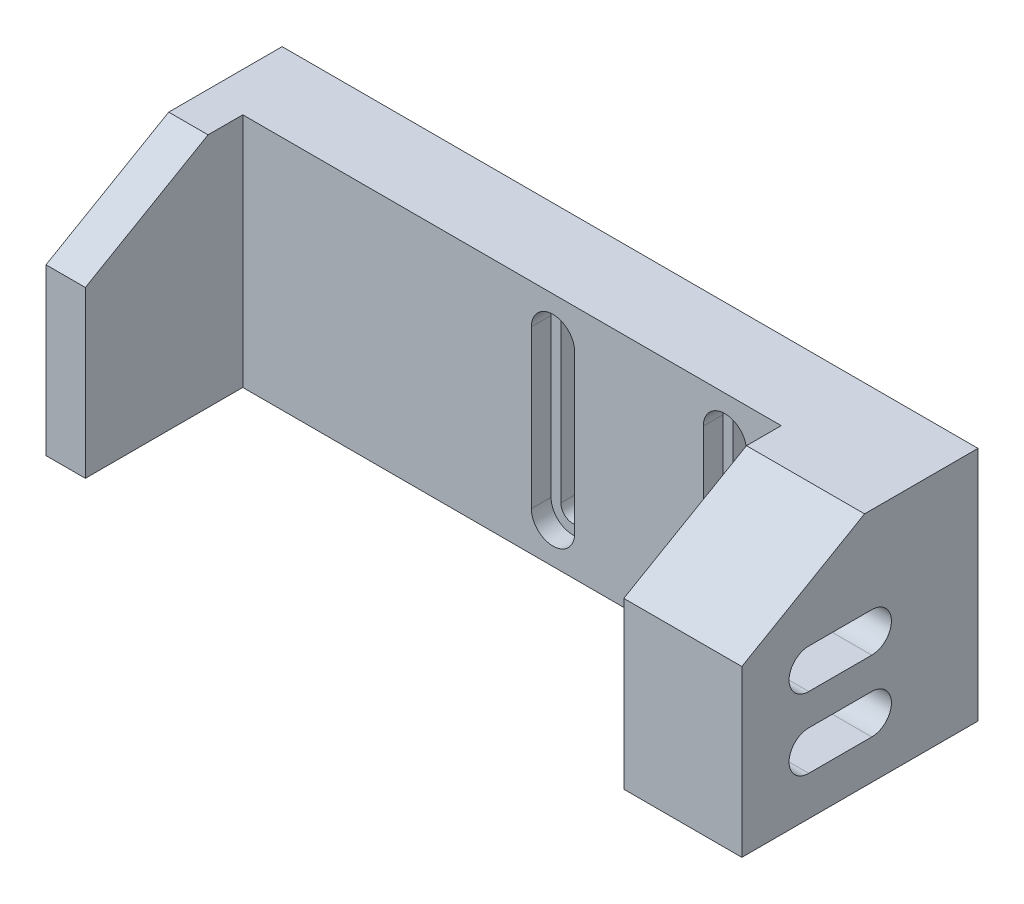
from build123d import *
from OCP.BRepFilletAPI import BRepFilletAPI_MakeChamfer

# Parameters (mm, degrees)
BOSS_EXTRUDE1_DEPTH = 30
CUT_EXTRUDE1_REACH  = 87.273
CHAMFER1_SIZE       = 9
CHAMFER1_SIZE2      = 15.588457268
BOSS_EXTRUDE8_DEPTH = 10
CUT_EXTRUDE2_REACH  = 66.966
CUT_EXTRUDE3_DEPTH  = 2.5


with BuildPart() as part:
    # Sketch1 → Boss-Extrude1 (new body)
    with BuildSketch(Plane(origin=(0, 0, 0), x_dir=(1, 0, 0), z_dir=(0, 1, 0))):
        Polygon((39.2, 15), (-39.2, 15), (-39.2, -15), (-34.2, -15), (-34.2, 5), (34.2, 5), (34.2, -15), (39.2, -15), align=None)
    extrude(amount=BOSS_EXTRUDE1_DEPTH)

    # Sketch2 → Cut-Extrude1 (cut, up to next)
    with BuildSketch(Plane(origin=(39.2, 0, 0), x_dir=(0, 0, -1), z_dir=(1, 0, 0)), mode=Mode.PRIVATE) as cut_extrude1_sk1:
        with BuildLine():
            Line((-6.5, 10), (1.5, 10))
            ThreePointArc((1.5, 10), (4, 7.5), (1.5, 5))
            Line((1.5, 5), (-6.5, 5))
            ThreePointArc((-6.5, 5), (-9, 7.5), (-6.5, 10))
        make_face()
    cut_extrude1_tool1 = extrude(cut_extrude1_sk1.sketch, amount=-CUT_EXTRUDE1_REACH, mode=Mode.PRIVATE) & part.part
    # Sketch2 → Cut-Extrude1 (cut, up to next)
    with BuildSketch(Plane(origin=(39.2, 0, 0), x_dir=(0, 0, -1), z_dir=(1, 0, 0)), mode=Mode.PRIVATE) as cut_extrude1_sk2:
        with BuildLine():
            Line((-6.5, 19), (1.5, 19))
            ThreePointArc((1.5, 19), (4, 16.5), (1.5, 14))
            Line((1.5, 14), (-6.5, 14))
            ThreePointArc((-6.5, 14), (-9, 16.5), (-6.5, 19))
        make_face()
    cut_extrude1_tool2 = extrude(cut_extrude1_sk2.sketch, amount=-CUT_EXTRUDE1_REACH, mode=Mode.PRIVATE) & part.part
    add(cut_extrude1_tool1.solids().sort_by_distance((39.2, 7.5, 2.5))[0], mode=Mode.SUBTRACT)
    add(cut_extrude1_tool2.solids().sort_by_distance((39.2, 16.5, 2.5))[0], mode=Mode.SUBTRACT)

    # Chamfer1: one chamfer whose edges measure the first distance from different faces: ONE call of the kernel's chamfer builder (chamfer() names one face for all edges)
    chamfer1_edges_1 = [part.edges().sort_by_distance(p)[0] for p in [
        (36.7, 30, 15),
    ]]
    chamfer1_side_1 = [part.faces().sort_by_distance(p)[0] for p in [
        (36.7, 15, 15),
    ]]
    chamfer1_edges_2 = [part.edges().sort_by_distance(p)[0] for p in [
        (-36.7, 30, 15),
    ]]
    chamfer1_side_2 = [part.faces().sort_by_distance(p)[0] for p in [
        (-36.7, 15, 15),
    ]]
    chamfer1 = BRepFilletAPI_MakeChamfer(part.part.solid().wrapped)
    for e in chamfer1_edges_1:
        chamfer1.Add(CHAMFER1_SIZE, CHAMFER1_SIZE2, e.wrapped, chamfer1_side_1[0].wrapped)  # the first distance lies on this face
    for e in chamfer1_edges_2:
        chamfer1.Add(CHAMFER1_SIZE, CHAMFER1_SIZE2, e.wrapped, chamfer1_side_2[0].wrapped)  # the first distance lies on this face
    add(Compound.cast(chamfer1.Shape()), mode=Mode.REPLACE)

    # Sketch8 → Boss-Extrude8 (add)
    with BuildSketch(Plane(origin=(39.2, 0, 0), x_dir=(0, 0, -1), z_dir=(1, 0, 0))):
        Polygon((15, 30), (0.588457268, 30), (-15, 21), (-15, 0), (15, 0), align=None)
        with BuildLine():
            Line((-6.5, 19), (1.5, 19))
            ThreePointArc((1.5, 19), (4, 16.5), (1.5, 14))
            Line((1.5, 14), (-6.5, 14))
            ThreePointArc((-6.5, 14), (-9, 16.5), (-6.5, 19))
        make_face(mode=Mode.SUBTRACT)
        with BuildLine():
            Line((-6.5, 10), (1.5, 10))
            ThreePointArc((1.5, 10), (4, 7.5), (1.5, 5))
            Line((1.5, 5), (-6.5, 5))
            ThreePointArc((-6.5, 5), (-9, 7.5), (-6.5, 10))
        make_face(mode=Mode.SUBTRACT)
    extrude(amount=BOSS_EXTRUDE8_DEPTH)

    # Sketch9 → Cut-Extrude2 (cut, up to next)
    with BuildSketch(Plane(origin=(0, 0, -15), x_dir=(-1, 0, 0), z_dir=(0, 0, -1)), mode=Mode.PRIVATE) as cut_extrude2_sk1:
        with BuildLine():
            ThreePointArc((-25.55, 25), (-27.05, 23.5), (-28.55, 25))
            Line((-28.55, 25), (-28.55, 5))
            ThreePointArc((-28.55, 5), (-27.05, 6.5), (-25.55, 5))
            Line((-25.55, 5), (-25.55, 25))
        make_face()
    cut_extrude2_tool1 = extrude(cut_extrude2_sk1.sketch, amount=-CUT_EXTRUDE2_REACH, mode=Mode.PRIVATE) & part.part
    # Sketch9 → Cut-Extrude2 (cut, up to next)
    with BuildSketch(Plane(origin=(0, 0, -15), x_dir=(-1, 0, 0), z_dir=(0, 0, -1)), mode=Mode.PRIVATE) as cut_extrude2_sk2:
        with BuildLine():
            ThreePointArc((-25.55, 25), (-27.05, 26.5), (-28.55, 25))
            Line((-28.55, 25), (-25.55, 25))
        make_face()
    cut_extrude2_tool2 = extrude(cut_extrude2_sk2.sketch, amount=-CUT_EXTRUDE2_REACH, mode=Mode.PRIVATE) & part.part
    # Sketch9 → Cut-Extrude2 (cut, up to next)
    with BuildSketch(Plane(origin=(0, 0, -15), x_dir=(-1, 0, 0), z_dir=(0, 0, -1)), mode=Mode.PRIVATE) as cut_extrude2_sk3:
        with BuildLine():
            Line((-25.55, 25), (-28.55, 25))
            ThreePointArc((-28.55, 25), (-27.05, 23.5), (-25.55, 25))
        make_face()
    cut_extrude2_tool3 = extrude(cut_extrude2_sk3.sketch, amount=-CUT_EXTRUDE2_REACH, mode=Mode.PRIVATE) & part.part
    # Sketch9 → Cut-Extrude2 (cut, up to next)
    with BuildSketch(Plane(origin=(0, 0, -15), x_dir=(-1, 0, 0), z_dir=(0, 0, -1)), mode=Mode.PRIVATE) as cut_extrude2_sk4:
        with BuildLine():
            ThreePointArc((-3.71, 25), (-5.21, 26.5), (-6.71, 25))
            Line((-6.71, 25), (-3.71, 25))
        make_face()
    cut_extrude2_tool4 = extrude(cut_extrude2_sk4.sketch, amount=-CUT_EXTRUDE2_REACH, mode=Mode.PRIVATE) & part.part
    # Sketch9 → Cut-Extrude2 (cut, up to next)
    with BuildSketch(Plane(origin=(0, 0, -15), x_dir=(-1, 0, 0), z_dir=(0, 0, -1)), mode=Mode.PRIVATE) as cut_extrude2_sk5:
        with BuildLine():
            Line((-3.71, 25), (-6.71, 25))
            ThreePointArc((-6.71, 25), (-5.21, 23.5), (-3.71, 25))
        make_face()
    cut_extrude2_tool5 = extrude(cut_extrude2_sk5.sketch, amount=-CUT_EXTRUDE2_REACH, mode=Mode.PRIVATE) & part.part
    # Sketch9 → Cut-Extrude2 (cut, up to next)
    with BuildSketch(Plane(origin=(0, 0, -15), x_dir=(-1, 0, 0), z_dir=(0, 0, -1)), mode=Mode.PRIVATE) as cut_extrude2_sk6:
        with BuildLine():
            ThreePointArc((-3.71, 25), (-5.21, 23.5), (-6.71, 25))
            Line((-6.71, 25), (-6.71, 5))
            ThreePointArc((-6.71, 5), (-5.21, 6.5), (-3.71, 5))
            Line((-3.71, 5), (-3.71, 25))
        make_face()
    cut_extrude2_tool6 = extrude(cut_extrude2_sk6.sketch, amount=-CUT_EXTRUDE2_REACH, mode=Mode.PRIVATE) & part.part
    # Sketch9 → Cut-Extrude2 (cut, up to next)
    with BuildSketch(Plane(origin=(0, 0, -15), x_dir=(-1, 0, 0), z_dir=(0, 0, -1)), mode=Mode.PRIVATE) as cut_extrude2_sk7:
        with BuildLine():
            ThreePointArc((-3.71, 25), (-5.21, 26.5), (-6.71, 25))
            Line((-6.71, 25), (-3.71, 25))
        make_face()
    cut_extrude2_tool7 = extrude(cut_extrude2_sk7.sketch, amount=-CUT_EXTRUDE2_REACH, mode=Mode.PRIVATE) & part.part
    # Sketch9 → Cut-Extrude2 (cut, up to next)
    with BuildSketch(Plane(origin=(0, 0, -15), x_dir=(-1, 0, 0), z_dir=(0, 0, -1)), mode=Mode.PRIVATE) as cut_extrude2_sk8:
        with BuildLine():
            Line((-3.71, 25), (-6.71, 25))
            ThreePointArc((-6.71, 25), (-5.21, 23.5), (-3.71, 25))
        make_face()
    cut_extrude2_tool8 = extrude(cut_extrude2_sk8.sketch, amount=-CUT_EXTRUDE2_REACH, mode=Mode.PRIVATE) & part.part
    # Sketch9 → Cut-Extrude2 (cut, up to next)
    with BuildSketch(Plane(origin=(0, 0, -15), x_dir=(-1, 0, 0), z_dir=(0, 0, -1)), mode=Mode.PRIVATE) as cut_extrude2_sk9:
        with BuildLine():
            ThreePointArc((-25.55, 25), (-27.05, 26.5), (-28.55, 25))
            Line((-28.55, 25), (-25.55, 25))
        make_face()
    cut_extrude2_tool9 = extrude(cut_extrude2_sk9.sketch, amount=-CUT_EXTRUDE2_REACH, mode=Mode.PRIVATE) & part.part
    # Sketch9 → Cut-Extrude2 (cut, up to next)
    with BuildSketch(Plane(origin=(0, 0, -15), x_dir=(-1, 0, 0), z_dir=(0, 0, -1)), mode=Mode.PRIVATE) as cut_extrude2_sk10:
        with BuildLine():
            Line((-25.55, 25), (-28.55, 25))
            ThreePointArc((-28.55, 25), (-27.05, 23.5), (-25.55, 25))
        make_face()
    cut_extrude2_tool10 = extrude(cut_extrude2_sk10.sketch, amount=-CUT_EXTRUDE2_REACH, mode=Mode.PRIVATE) & part.part
    # Sketch9 → Cut-Extrude2 (cut, up to next)
    with BuildSketch(Plane(origin=(0, 0, -15), x_dir=(-1, 0, 0), z_dir=(0, 0, -1)), mode=Mode.PRIVATE) as cut_extrude2_sk11:
        with BuildLine():
            ThreePointArc((-25.55, 5), (-27.05, 6.5), (-28.55, 5))
            Line((-28.55, 5), (-25.55, 5))
        make_face()
    cut_extrude2_tool11 = extrude(cut_extrude2_sk11.sketch, amount=-CUT_EXTRUDE2_REACH, mode=Mode.PRIVATE) & part.part
    # Sketch9 → Cut-Extrude2 (cut, up to next)
    with BuildSketch(Plane(origin=(0, 0, -15), x_dir=(-1, 0, 0), z_dir=(0, 0, -1)), mode=Mode.PRIVATE) as cut_extrude2_sk12:
        with BuildLine():
            Line((-25.55, 5), (-28.55, 5))
            ThreePointArc((-28.55, 5), (-27.05, 3.5), (-25.55, 5))
        make_face()
    cut_extrude2_tool12 = extrude(cut_extrude2_sk12.sketch, amount=-CUT_EXTRUDE2_REACH, mode=Mode.PRIVATE) & part.part
    # Sketch9 → Cut-Extrude2 (cut, up to next)
    with BuildSketch(Plane(origin=(0, 0, -15), x_dir=(-1, 0, 0), z_dir=(0, 0, -1)), mode=Mode.PRIVATE) as cut_extrude2_sk13:
        with BuildLine():
            ThreePointArc((-25.55, 5), (-27.05, 6.5), (-28.55, 5))
            Line((-28.55, 5), (-25.55, 5))
        make_face()
    cut_extrude2_tool13 = extrude(cut_extrude2_sk13.sketch, amount=-CUT_EXTRUDE2_REACH, mode=Mode.PRIVATE) & part.part
    # Sketch9 → Cut-Extrude2 (cut, up to next)
    with BuildSketch(Plane(origin=(0, 0, -15), x_dir=(-1, 0, 0), z_dir=(0, 0, -1)), mode=Mode.PRIVATE) as cut_extrude2_sk14:
        with BuildLine():
            Line((-25.55, 5), (-28.55, 5))
            ThreePointArc((-28.55, 5), (-27.05, 3.5), (-25.55, 5))
        make_face()
    cut_extrude2_tool14 = extrude(cut_extrude2_sk14.sketch, amount=-CUT_EXTRUDE2_REACH, mode=Mode.PRIVATE) & part.part
    # Sketch9 → Cut-Extrude2 (cut, up to next)
    with BuildSketch(Plane(origin=(0, 0, -15), x_dir=(-1, 0, 0), z_dir=(0, 0, -1)), mode=Mode.PRIVATE) as cut_extrude2_sk15:
        with BuildLine():
            ThreePointArc((-3.71, 5), (-5.21, 6.5), (-6.71, 5))
            Line((-6.71, 5), (-3.71, 5))
        make_face()
    cut_extrude2_tool15 = extrude(cut_extrude2_sk15.sketch, amount=-CUT_EXTRUDE2_REACH, mode=Mode.PRIVATE) & part.part
    # Sketch9 → Cut-Extrude2 (cut, up to next)
    with BuildSketch(Plane(origin=(0, 0, -15), x_dir=(-1, 0, 0), z_dir=(0, 0, -1)), mode=Mode.PRIVATE) as cut_extrude2_sk16:
        with BuildLine():
            Line((-3.71, 5), (-6.71, 5))
            ThreePointArc((-6.71, 5), (-5.21, 3.5), (-3.71, 5))
        make_face()
    cut_extrude2_tool16 = extrude(cut_extrude2_sk16.sketch, amount=-CUT_EXTRUDE2_REACH, mode=Mode.PRIVATE) & part.part
    # Sketch9 → Cut-Extrude2 (cut, up to next)
    with BuildSketch(Plane(origin=(0, 0, -15), x_dir=(-1, 0, 0), z_dir=(0, 0, -1)), mode=Mode.PRIVATE) as cut_extrude2_sk17:
        with BuildLine():
            ThreePointArc((-3.71, 5), (-5.21, 6.5), (-6.71, 5))
            Line((-6.71, 5), (-3.71, 5))
        make_face()
    cut_extrude2_tool17 = extrude(cut_extrude2_sk17.sketch, amount=-CUT_EXTRUDE2_REACH, mode=Mode.PRIVATE) & part.part
    # Sketch9 → Cut-Extrude2 (cut, up to next)
    with BuildSketch(Plane(origin=(0, 0, -15), x_dir=(-1, 0, 0), z_dir=(0, 0, -1)), mode=Mode.PRIVATE) as cut_extrude2_sk18:
        with BuildLine():
            Line((-3.71, 5), (-6.71, 5))
            ThreePointArc((-6.71, 5), (-5.21, 3.5), (-3.71, 5))
        make_face()
    cut_extrude2_tool18 = extrude(cut_extrude2_sk18.sketch, amount=-CUT_EXTRUDE2_REACH, mode=Mode.PRIVATE) & part.part
    add(cut_extrude2_tool1.solids().sort_by_distance((27.05, 15, -15))[0], mode=Mode.SUBTRACT)
    add(cut_extrude2_tool2.solids().sort_by_distance((27.05, 25.63662, -15))[0], mode=Mode.SUBTRACT)
    add(cut_extrude2_tool3.solids().sort_by_distance((27.05, 24.36338, -15))[0], mode=Mode.SUBTRACT)
    add(cut_extrude2_tool4.solids().sort_by_distance((5.21, 25.63662, -15))[0], mode=Mode.SUBTRACT)
    add(cut_extrude2_tool5.solids().sort_by_distance((5.21, 24.36338, -15))[0], mode=Mode.SUBTRACT)
    add(cut_extrude2_tool6.solids().sort_by_distance((5.21, 15, -15))[0], mode=Mode.SUBTRACT)
    add(cut_extrude2_tool7.solids().sort_by_distance((5.21, 25.63662, -15))[0], mode=Mode.SUBTRACT)
    add(cut_extrude2_tool8.solids().sort_by_distance((5.21, 24.36338, -15))[0], mode=Mode.SUBTRACT)
    add(cut_extrude2_tool9.solids().sort_by_distance((27.05, 25.63662, -15))[0], mode=Mode.SUBTRACT)
    add(cut_extrude2_tool10.solids().sort_by_distance((27.05, 24.36338, -15))[0], mode=Mode.SUBTRACT)
    add(cut_extrude2_tool11.solids().sort_by_distance((27.05, 5.63662, -15))[0], mode=Mode.SUBTRACT)
    add(cut_extrude2_tool12.solids().sort_by_distance((27.05, 4.36338, -15))[0], mode=Mode.SUBTRACT)
    add(cut_extrude2_tool13.solids().sort_by_distance((27.05, 5.63662, -15))[0], mode=Mode.SUBTRACT)
    add(cut_extrude2_tool14.solids().sort_by_distance((27.05, 4.36338, -15))[0], mode=Mode.SUBTRACT)
    add(cut_extrude2_tool15.solids().sort_by_distance((5.21, 5.63662, -15))[0], mode=Mode.SUBTRACT)
    add(cut_extrude2_tool16.solids().sort_by_distance((5.21, 4.36338, -15))[0], mode=Mode.SUBTRACT)
    add(cut_extrude2_tool17.solids().sort_by_distance((5.21, 5.63662, -15))[0], mode=Mode.SUBTRACT)
    add(cut_extrude2_tool18.solids().sort_by_distance((5.21, 4.36338, -15))[0], mode=Mode.SUBTRACT)

    # Sketch10 → Cut-Extrude3 (cut)
    with BuildSketch(Plane.XY.offset(-5)):
        with BuildLine():
            Line((7.96, 5), (7.96, 25))
            ThreePointArc((7.96, 25), (5.21, 27.75), (2.46, 25))
            Line((2.46, 25), (2.46, 5))
            ThreePointArc((2.46, 5), (5.21, 2.25), (7.96, 5))
        make_face()
        with BuildLine():
            ThreePointArc((3.71, 25), (5.21, 26.5), (6.71, 25))
            Line((6.71, 25), (6.71, 5))
            ThreePointArc((6.71, 5), (5.21, 3.5), (3.71, 5))
            Line((3.71, 5), (3.71, 25))
        make_face(mode=Mode.SUBTRACT)
        with BuildLine():
            Line((29.8, 5), (29.8, 25))
            ThreePointArc((29.8, 25), (27.05, 27.75), (24.3, 25))
            Line((24.3, 25), (24.3, 5))
            ThreePointArc((24.3, 5), (27.05, 2.25), (29.8, 5))
        make_face()
        with BuildLine():
            ThreePointArc((25.55, 25), (27.05, 26.5), (28.55, 25))
            Line((28.55, 25), (28.55, 5))
            ThreePointArc((28.55, 5), (27.05, 3.5), (25.55, 5))
            Line((25.55, 5), (25.55, 25))
        make_face(mode=Mode.SUBTRACT)
    extrude(amount=-CUT_EXTRUDE3_DEPTH, mode=Mode.SUBTRACT)


solid = part.part
